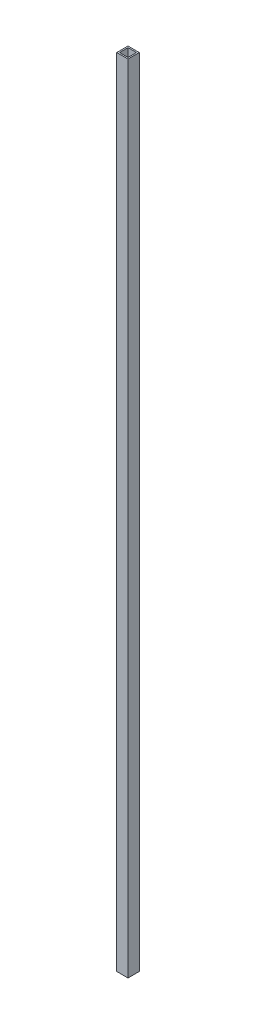
from build123d import *

# Parameters (mm, degrees)
SCHIZZO1_W                   = 40
SCHIZZO1_H                   = 40
SCHIZZO1_W_2                 = 30
SCHIZZO1_H_2                 = 30
ESTRUSIONE_ESTRUSIONE1_DEPTH = 1408.5


with BuildPart() as part:
    # Schizzo1 → Estrusione-Estrusione1 (new body, symmetric)
    with BuildSketch(Plane(origin=(0, 0, 0), x_dir=(1, 0, 0), z_dir=(0, 1, 0))):
        Rectangle(SCHIZZO1_W, SCHIZZO1_H)
        Rectangle(SCHIZZO1_W_2, SCHIZZO1_H_2, mode=Mode.SUBTRACT)
    extrude(amount=ESTRUSIONE_ESTRUSIONE1_DEPTH, both=True)


solid = part.part
